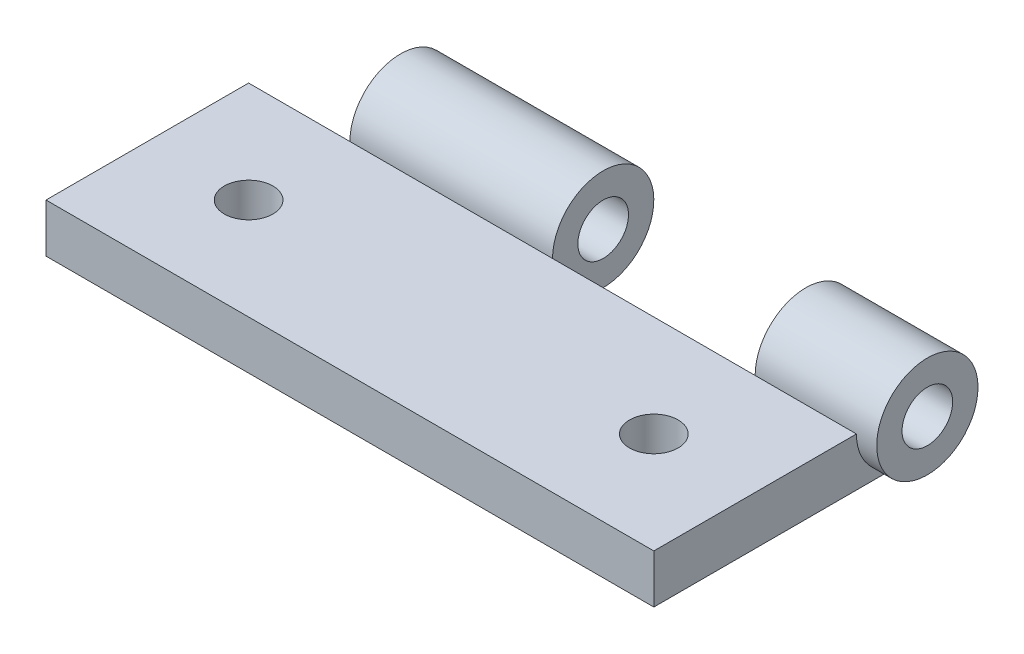
from build123d import *

# Parameters (mm, degrees)
SKETCH1_W                    = 38.1
SKETCH1_H                    = 15.875
BOSS_EXTRUDE1_DEPTH          = 3.048
SKETCH2_R                    = 3.175
BOSS_EXTRUDE2_DEPTH          = 1.27
BOSS_EXTRUDE2_DEPTH_BACK     = 39.37
SKETCH7_W                    = 12.7
SKETCH7_H                    = 6.35
CUT_EXTRUDE_THIN2_DEPTH      = 7.223
CUT_EXTRUDE_THIN2_DEPTH_BACK = 1.127
SKETCH8_R                    = 1.5875
CUT_EXTRUDE2_DEPTH           = 40.37
SKETCH9_R                    = 1.524
CUT_EXTRUDE3_DEPTH           = 4.175


with BuildPart() as part:
    # Sketch1 → Boss-Extrude1 (new body)
    with BuildSketch(Plane(origin=(0, 0, 0), x_dir=(1, 0, 0), z_dir=(0, 1, 0))):
        Rectangle(SKETCH1_W, SKETCH1_H)
    extrude(amount=BOSS_EXTRUDE1_DEPTH)

    # Sketch2 → Boss-Extrude2 (add, two sides)
    with BuildSketch(Plane(origin=(19.05, 0, 0), x_dir=(0, 0, -1), z_dir=(1, 0, 0))) as boss_extrude2_sk:
        with Locations((7.9375, 3.048)):
            Circle(SKETCH2_R)
    extrude(amount=BOSS_EXTRUDE2_DEPTH)
    extrude(boss_extrude2_sk.sketch, amount=-BOSS_EXTRUDE2_DEPTH_BACK)

    # Sketch7 → Cut-Extrude-Thin2 (cut, two sides)
    with BuildSketch(Plane(origin=(0, 0, 0), x_dir=(1, 0, 0), z_dir=(0, 1, 0))) as cut_extrude_thin2_sk:
        with Locations((-19.05, 7.9375)):
            Rectangle(SKETCH7_W, SKETCH7_H)
        with Locations((6.35, 7.9375)):
            Rectangle(SKETCH7_W, SKETCH7_H)
    extrude(amount=CUT_EXTRUDE_THIN2_DEPTH, mode=Mode.SUBTRACT)
    extrude(cut_extrude_thin2_sk.sketch, amount=-CUT_EXTRUDE_THIN2_DEPTH_BACK, mode=Mode.SUBTRACT)

    # Sketch8 → Cut-Extrude2 (cut, through all)
    with BuildSketch(Plane(origin=(20.32, 0, 0), x_dir=(0, 0, -1), z_dir=(1, 0, 0))):
        with Locations((7.9375, 3.048)):
            Circle(SKETCH8_R)
    extrude(amount=-CUT_EXTRUDE2_DEPTH, mode=Mode.SUBTRACT)

    # Sketch9 → Cut-Extrude3 (cut, through all)
    with BuildSketch(Plane(origin=(0, 3.048, 0), x_dir=(1, 0, 0), z_dir=(0, 1, 0))):
        with Locations((-12.7, -1.5875)):
            Circle(SKETCH9_R)
        with Locations((12.7, -1.5875)):
            Circle(SKETCH9_R)
    extrude(amount=-CUT_EXTRUDE3_DEPTH, mode=Mode.SUBTRACT)


solid = part.part
